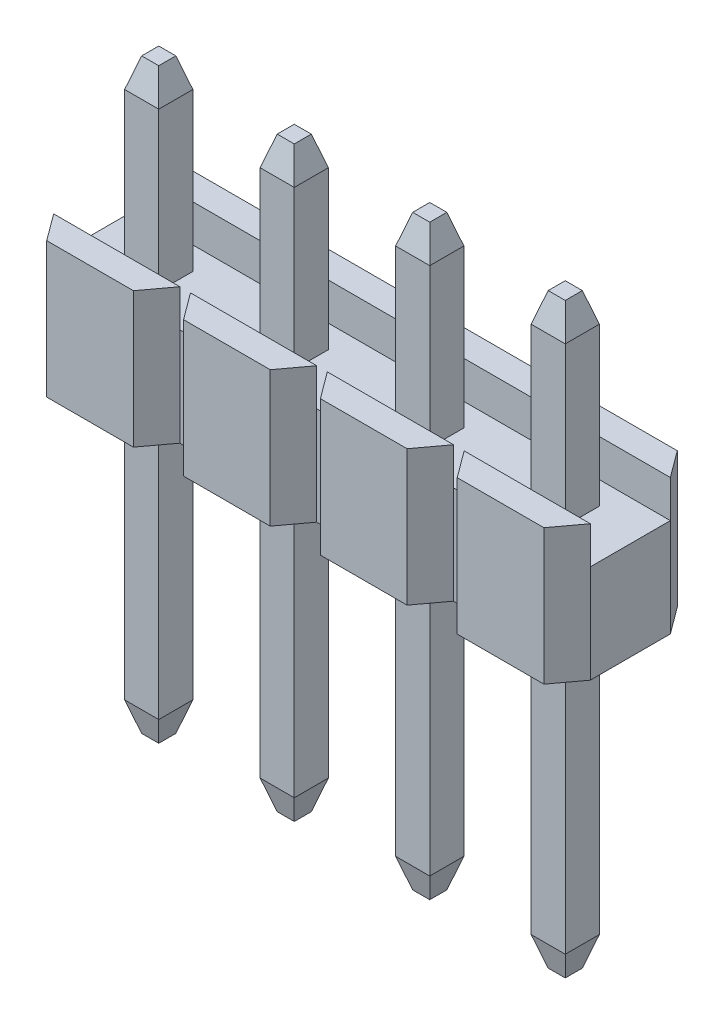
from build123d import *

# Parameters (mm, degrees)
BOSS_EXTRUDE1_DEPTH      = 2.54
SKETCH5_W                = 10.06
SKETCH5_H                = 1.5
CUT_EXTRUDE3_DEPTH       = 0.7
SKETCH3_W                = 0.64
SKETCH3_H                = 0.64
CUT_EXTRUDE2_DEPTH       = 3.54
SKETCH4_W                = 0.64
SKETCH4_H                = 0.64
BOSS_EXTRUDE2_DEPTH      = 8.2
BOSS_EXTRUDE2_DEPTH_BACK = 2.8
CHAMFER1_SIZE            = 0.16
CHAMFER1_SIZE2           = 0.5458
CHAMFER1_PART_2_SIZE     = 0.16
CHAMFER1_PART_2_SIZE2    = 0.5458
CHAMFER1_PART_3_SIZE     = 0.16
CHAMFER1_PART_3_SIZE2    = 0.5458
CHAMFER1_PART_4_SIZE     = 0.16
CHAMFER1_PART_4_SIZE2    = 0.5458
CHAMFER2_SIZE            = 0.16
CHAMFER2_SIZE2           = 0.5458
CHAMFER2_PART_2_SIZE     = 0.16
CHAMFER2_PART_2_SIZE2    = 0.5458
CHAMFER2_PART_3_SIZE     = 0.16
CHAMFER2_PART_3_SIZE2    = 0.5458
CHAMFER2_PART_4_SIZE     = 0.16
CHAMFER2_PART_4_SIZE2    = 0.5458


with BuildPart() as part:
    # Sketch1 → Boss-Extrude1 (new body)
    with BuildSketch(Plane(origin=(0, 0, 0), x_dir=(1, 0, 0), z_dir=(0, 1, 0))):
        Polygon((-4.660019462, -1.25), (-3.034980538, -1.25), (-2.665, -0.75), (-2.465, -0.75), (-2.095019462, -1.25), (-0.469980538, -1.25), (-0.1, -0.75), (0.1, -0.75), (0.469980538, -1.25), (2.095019462, -1.25), (2.465, -0.75), (2.665, -0.75), (3.034980538, -1.25), (4.660019462, -1.25), (5.03, -0.75), (5.03, 0.75), (4.660019462, 1.25), (3.034980538, 1.25), (2.665, 0.75), (2.465, 0.75), (2.095019462, 1.25), (0.469980538, 1.25), (0.1, 0.75), (-0.1, 0.75), (-0.469980538, 1.25), (-2.095019462, 1.25), (-2.465, 0.75), (-2.665, 0.75), (-3.034980538, 1.25), (-4.660019462, 1.25), (-5.03, 0.75), (-5.03, -0.75), align=None)
    extrude(amount=-BOSS_EXTRUDE1_DEPTH)

    # Sketch5 → Cut-Extrude3 (cut)
    with BuildSketch(Plane(origin=(0, 0, 0), x_dir=(1, 0, 0), z_dir=(0, 1, 0))):
        Rectangle(SKETCH5_W, SKETCH5_H)
    extrude(amount=-CUT_EXTRUDE3_DEPTH, mode=Mode.SUBTRACT)

    # Sketch3 → Cut-Extrude2 (cut, through all)
    with BuildSketch(Plane(origin=(0, -2.54, 0), x_dir=(-1, 0, 0), z_dir=(0, -1, 0))):
        with Locations((-3.81, 0)):
            Rectangle(SKETCH3_W, SKETCH3_H)
        with Locations((-1.27, 0)):
            Rectangle(SKETCH3_W, SKETCH3_H)
        with Locations((1.27, 0)):
            Rectangle(SKETCH3_W, SKETCH3_H)
        with Locations((3.81, 0)):
            Rectangle(SKETCH3_W, SKETCH3_H)
    extrude(amount=-CUT_EXTRUDE2_DEPTH, mode=Mode.SUBTRACT)

    # Sketch4 → Boss-Extrude2 (add, two sides)
    with BuildSketch(Plane.XZ) as boss_extrude2_sk:
        with Locations((3.81, 0)):
            Rectangle(SKETCH4_W, SKETCH4_H)
        with Locations((1.27, 0)):
            Rectangle(SKETCH4_W, SKETCH4_H)
        with Locations((-1.27, 0)):
            Rectangle(SKETCH4_W, SKETCH4_H)
        with Locations((-3.81, 0)):
            Rectangle(SKETCH4_W, SKETCH4_H)
    extrude(amount=BOSS_EXTRUDE2_DEPTH)
    extrude(boss_extrude2_sk.sketch, amount=-BOSS_EXTRUDE2_DEPTH_BACK)

    # Chamfer1
    chamfer1_edges = [part.edges().sort_by_distance(p)[0] for p in [
        (3.49, -8.2, 0),
        (3.81, -8.2, -0.32),
        (4.13, -8.2, 0),
        (3.81, -8.2, 0.32),
    ]]
    chamfer1_side = [part.faces().sort_by_distance(p)[0] for p in [
        (3.81, -8.2, 0),
    ]]
    chamfer(chamfer1_edges, length=CHAMFER1_SIZE, length2=CHAMFER1_SIZE2, reference=chamfer1_side[0])

    # Chamfer1 part 2
    chamfer1_part_2_edges = [part.edges().sort_by_distance(p)[0] for p in [
        (0.95, -8.2, 0),
        (1.27, -8.2, -0.32),
        (1.59, -8.2, 0),
        (1.27, -8.2, 0.32),
    ]]
    chamfer1_part_2_side = [part.faces().sort_by_distance(p)[0] for p in [
        (1.27, -8.2, 0),
    ]]
    chamfer(chamfer1_part_2_edges, length=CHAMFER1_PART_2_SIZE, length2=CHAMFER1_PART_2_SIZE2, reference=chamfer1_part_2_side[0])

    # Chamfer1 part 3
    chamfer1_part_3_edges = [part.edges().sort_by_distance(p)[0] for p in [
        (-1.59, -8.2, 0),
        (-1.27, -8.2, -0.32),
        (-0.95, -8.2, 0),
        (-1.27, -8.2, 0.32),
    ]]
    chamfer1_part_3_side = [part.faces().sort_by_distance(p)[0] for p in [
        (-1.27, -8.2, 0),
    ]]
    chamfer(chamfer1_part_3_edges, length=CHAMFER1_PART_3_SIZE, length2=CHAMFER1_PART_3_SIZE2, reference=chamfer1_part_3_side[0])

    # Chamfer1 part 4
    chamfer1_part_4_edges = [part.edges().sort_by_distance(p)[0] for p in [
        (-4.13, -8.2, 0),
        (-3.81, -8.2, -0.32),
        (-3.49, -8.2, 0),
        (-3.81, -8.2, 0.32),
    ]]
    chamfer1_part_4_side = [part.faces().sort_by_distance(p)[0] for p in [
        (-3.81, -8.2, 0),
    ]]
    chamfer(chamfer1_part_4_edges, length=CHAMFER1_PART_4_SIZE, length2=CHAMFER1_PART_4_SIZE2, reference=chamfer1_part_4_side[0])

    # Chamfer2
    chamfer2_edges = [part.edges().sort_by_distance(p)[0] for p in [
        (3.49, 2.8, 0),
        (3.81, 2.8, -0.32),
        (4.13, 2.8, 0),
        (3.81, 2.8, 0.32),
    ]]
    chamfer2_side = [part.faces().sort_by_distance(p)[0] for p in [
        (3.81, 2.8, 0),
    ]]
    chamfer(chamfer2_edges, length=CHAMFER2_SIZE, length2=CHAMFER2_SIZE2, reference=chamfer2_side[0])

    # Chamfer2 part 2
    chamfer2_part_2_edges = [part.edges().sort_by_distance(p)[0] for p in [
        (0.95, 2.8, 0),
        (1.27, 2.8, -0.32),
        (1.59, 2.8, 0),
        (1.27, 2.8, 0.32),
    ]]
    chamfer2_part_2_side = [part.faces().sort_by_distance(p)[0] for p in [
        (1.27, 2.8, 0),
    ]]
    chamfer(chamfer2_part_2_edges, length=CHAMFER2_PART_2_SIZE, length2=CHAMFER2_PART_2_SIZE2, reference=chamfer2_part_2_side[0])

    # Chamfer2 part 3
    chamfer2_part_3_edges = [part.edges().sort_by_distance(p)[0] for p in [
        (-1.59, 2.8, 0),
        (-1.27, 2.8, -0.32),
        (-0.95, 2.8, 0),
        (-1.27, 2.8, 0.32),
    ]]
    chamfer2_part_3_side = [part.faces().sort_by_distance(p)[0] for p in [
        (-1.27, 2.8, 0),
    ]]
    chamfer(chamfer2_part_3_edges, length=CHAMFER2_PART_3_SIZE, length2=CHAMFER2_PART_3_SIZE2, reference=chamfer2_part_3_side[0])

    # Chamfer2 part 4
    chamfer2_part_4_edges = [part.edges().sort_by_distance(p)[0] for p in [
        (-4.13, 2.8, 0),
        (-3.81, 2.8, -0.32),
        (-3.49, 2.8, 0),
        (-3.81, 2.8, 0.32),
    ]]
    chamfer2_part_4_side = [part.faces().sort_by_distance(p)[0] for p in [
        (-3.81, 2.8, 0),
    ]]
    chamfer(chamfer2_part_4_edges, length=CHAMFER2_PART_4_SIZE, length2=CHAMFER2_PART_4_SIZE2, reference=chamfer2_part_4_side[0])


solid = part.part
